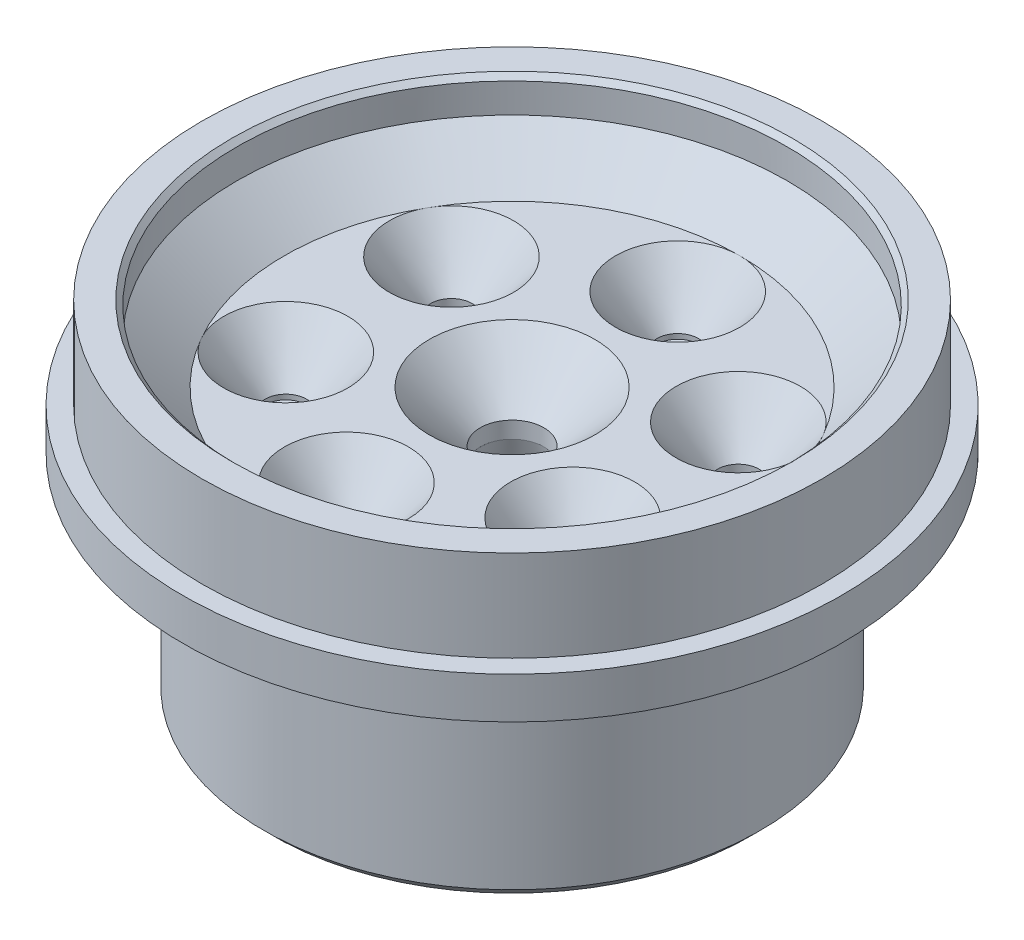
from build123d import *

# Parameters (mm, degrees)
CHAMFER1_SIZE      = 0.381
CHAMFER2_SIZE      = 0.762
CHAMFER4_SIZE      = 1.27
SKETCH3_R          = 1.5875
SKETCH2_R          = 4.7625
SKETCH5_R          = 2.4384
SKETCH4_R          = 6.35
SKETCH9_R          = 2.4384
CUT_EXTRUDE1_DEPTH = 1.27
SKETCH3_3_R        = 1.5875
CUT_EXTRUDE2_DEPTH = 0.381
SKETCH14_R         = 2.4384
SKETCH12_R         = 6.35
SKETCH16_R         = 1.5875
SKETCH15_R         = 4.7625
CIRPATTERN2_COUNT  = 6
SKETCH17_R         = 1.5875
CUT_EXTRUDE4_DEPTH = 25.4


with BuildPart() as part:
    # Sketch1 → Revolve1 (revolve)
    with BuildSketch(Plane.XY, mode=Mode.PRIVATE) as revolve1_sk:
        Polygon((0, 20.6756), (0, 0), (19.05, 0), (19.05, 14.5288), (22.2123, 14.5288), (22.2123, 16.3068), (25.273, 16.3068), (25.273, 19.4818), (23.7744, 19.4818), (23.7744, 26.4668), (21.1074, 26.4668), (21.1074, 23.8252), (17.4625, 20.6756), align=None)
    revolve(revolve1_sk.sketch.rotate(Axis((0, 0, 0), (0, 1, 0)), 90), axis=Axis((0, 0, 0), (0, 1, 0)))

    # Chamfer1
    chamfer1_edges = [part.edges().sort_by_distance(p)[0] for p in [
        (0, 26.4668, 21.1074),
    ]]
    chamfer(chamfer1_edges, length=CHAMFER1_SIZE)

    # Chamfer2
    chamfer2_edges = [part.edges().sort_by_distance(p)[0] for p in [
        (0, 0, 19.05),
    ]]
    chamfer(chamfer2_edges, length=CHAMFER2_SIZE)

    # Chamfer4
    chamfer4_edges = [part.edges().sort_by_distance(p)[0] for p in [
        (0, 14.5288, 19.05),
    ]]
    chamfer(chamfer4_edges, length=CHAMFER4_SIZE)

    # Sketch3 → Cut-Loft1 section 0
    with BuildSketch(Plane(origin=(0, 16.764, 0), x_dir=(1, 0, 0), z_dir=(0, 1, 0))):
        with Locations((0, 12.7)):
            Circle(SKETCH3_R)
    # Sketch2 → Cut-Loft1 section 1
    with BuildSketch(Plane(origin=(0, 20.6756, 0), x_dir=(1, 0, 0), z_dir=(0, 1, 0))):
        with Locations((0, 12.7)):
            Circle(SKETCH2_R)
    cut_loft1 = loft(mode=Mode.SUBTRACT)

    # Sketch5 → Cut-Loft3 section 0
    with BuildSketch(Plane(origin=(0, 16.764, 0), x_dir=(1, 0, 0), z_dir=(0, 1, 0))):
        Circle(SKETCH5_R)
    # Sketch4 → Cut-Loft3 section 1
    with BuildSketch(Plane(origin=(0, 20.6756, 0), x_dir=(1, 0, 0), z_dir=(0, 1, 0))):
        Circle(SKETCH4_R)
    loft(mode=Mode.SUBTRACT)

    # Sketch9 → Cut-Extrude1 (cut)
    with BuildSketch(Plane(origin=(0, 16.764, 0), x_dir=(1, 0, 0), z_dir=(0, 1, 0))):
        with Locations(Location((0, 0, 0), (0, 0, 270))):
            Circle(SKETCH9_R)
    extrude(amount=-CUT_EXTRUDE1_DEPTH, mode=Mode.SUBTRACT)

    # Sketch3_3 → Cut-Extrude2 (cut)
    with BuildSketch(Plane(origin=(0, 16.764, 0), x_dir=(1, 0, 0), z_dir=(0, 1, 0))):
        with Locations(Location((0, 12.7, 0), (0, 0, 270))):
            Circle(SKETCH3_3_R)
    cut_extrude2 = extrude(amount=-CUT_EXTRUDE2_DEPTH, mode=Mode.SUBTRACT)

    # Cut-Extrude3 cone 1 section (through the dimple's axis) → Cut-Extrude3 (revolve, cut)
    with BuildSketch(Plane(origin=(0, 16.383, -12.7), x_dir=(0, 0, 1), z_dir=(1, 0, 0))):
        Polygon((0, 0), (1.5875, 0), (0, 0.366503253), align=None)
    cut_extrude3 = revolve(axis=Axis((0, 16.383, -12.7), (0, -1, 0)), mode=Mode.SUBTRACT)

    # Sketch14 → Cut-Loft5 section 0
    with BuildSketch(Plane(origin=(0, 15.494, 0), x_dir=(1, 0, 0), z_dir=(0, 1, 0))):
        Circle(SKETCH14_R)
    # Sketch12 → Cut-Loft5 section 1
    with BuildSketch(Plane.XZ):
        Circle(SKETCH12_R)
    loft(mode=Mode.SUBTRACT)

    # Sketch16 → Cut-Loft7 section 0
    with BuildSketch(Plane(origin=(0, 12.573, 0), x_dir=(-1, 0, 0), z_dir=(0, -1, 0))):
        with Locations((0, 12.7)):
            Circle(SKETCH16_R)
    # Sketch15 → Cut-Loft7 section 1
    with BuildSketch(Plane.XZ):
        with Locations((0, -12.7)):
            Circle(SKETCH15_R)
    cut_loft7 = loft(mode=Mode.SUBTRACT)

    # CirPattern2: Cut-Loft1, Cut-Extrude2, Cut-Extrude3, Cut-Loft7 ×6 about axis
    cirpattern2_axis = Axis((0, 0, 0), (0, 1, 0))
    add([cut_loft1.rotate(cirpattern2_axis, i * 360 / CIRPATTERN2_COUNT) for i in range(1, CIRPATTERN2_COUNT)], mode=Mode.SUBTRACT)
    add([cut_extrude2.rotate(cirpattern2_axis, i * 360 / CIRPATTERN2_COUNT) for i in range(1, CIRPATTERN2_COUNT)], mode=Mode.SUBTRACT)
    add([cut_extrude3.rotate(cirpattern2_axis, i * 360 / CIRPATTERN2_COUNT) for i in range(1, CIRPATTERN2_COUNT)], mode=Mode.SUBTRACT)
    add([cut_loft7.rotate(cirpattern2_axis, i * 360 / CIRPATTERN2_COUNT) for i in range(1, CIRPATTERN2_COUNT)], mode=Mode.SUBTRACT)

    # Sketch17 → Cut-Extrude4 (cut)
    with BuildSketch(Plane(origin=(0, 20.6756, 0), x_dir=(1, 0, 0), z_dir=(0, 1, 0))):
        with Locations(Location((-10.998522628, 6.35, 0), (0, 0, 330))):
            Circle(SKETCH17_R)
        with Locations(Location((10.998522628, 6.35, 0), (0, 0, 210))):
            Circle(SKETCH17_R)
        with Locations(Location((0, -12.7, 0), (0, 0, 270))):
            Circle(SKETCH17_R)
    extrude(amount=-CUT_EXTRUDE4_DEPTH, mode=Mode.SUBTRACT)


solid = part.part
